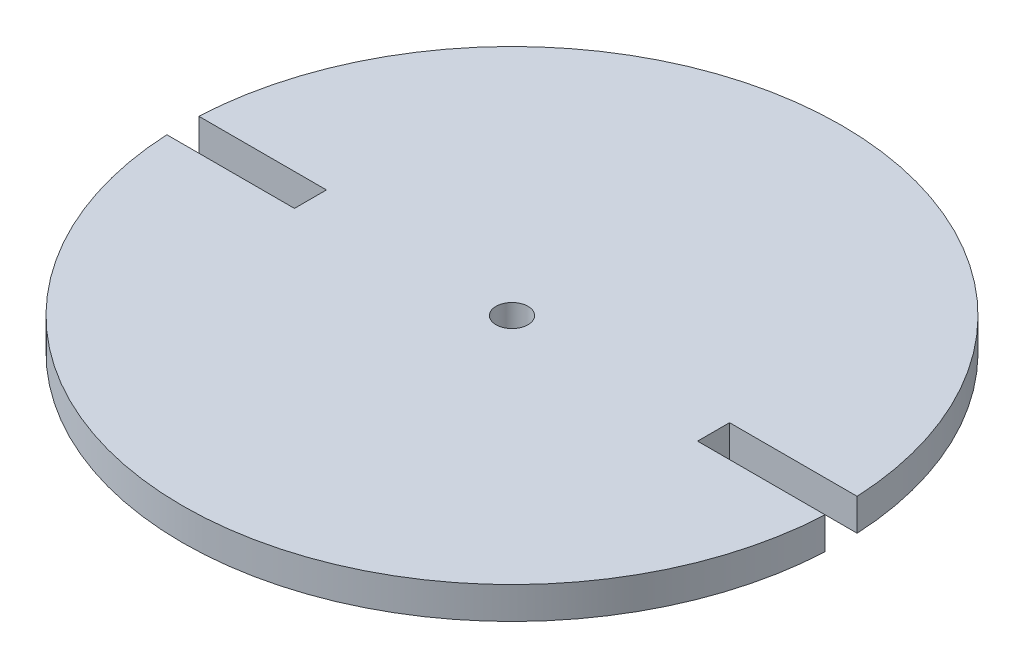
from build123d import *

# Parameters (mm, degrees)
SKETCH1_R           = 65.405
BOSS_EXTRUDE1_DEPTH = 6.35
SKETCH2_W           = 50.8
SKETCH2_H           = 6.35
CUT_EXTRUDE1_DEPTH  = 6.35
SKETCH7_R           = 3.175
CUT_EXTRUDE2_DEPTH  = 7.35


with BuildPart() as part:
    # Sketch1 → Boss-Extrude1 (new body)
    with BuildSketch(Plane(origin=(0, 0, 0), x_dir=(1, 0, 0), z_dir=(0, 1, 0))):
        Circle(SKETCH1_R)
    extrude(amount=BOSS_EXTRUDE1_DEPTH)

    # Sketch2 → Cut-Extrude1 (cut)
    with BuildSketch(Plane(origin=(0, 6.35, 0), x_dir=(1, 0, 0), z_dir=(0, 1, 0))):
        with Locations((-65.405, 0)):
            Rectangle(SKETCH2_W, SKETCH2_H)
        with Locations((65.405, 0)):
            Rectangle(SKETCH2_W, SKETCH2_H)
    extrude(amount=-CUT_EXTRUDE1_DEPTH, mode=Mode.SUBTRACT)

    # Sketch7 → Cut-Extrude2 (cut, through all)
    with BuildSketch(Plane(origin=(0, 6.35, 0), x_dir=(1, 0, 0), z_dir=(0, 1, 0))):
        Circle(SKETCH7_R)
    extrude(amount=-CUT_EXTRUDE2_DEPTH, mode=Mode.SUBTRACT)


solid = part.part
